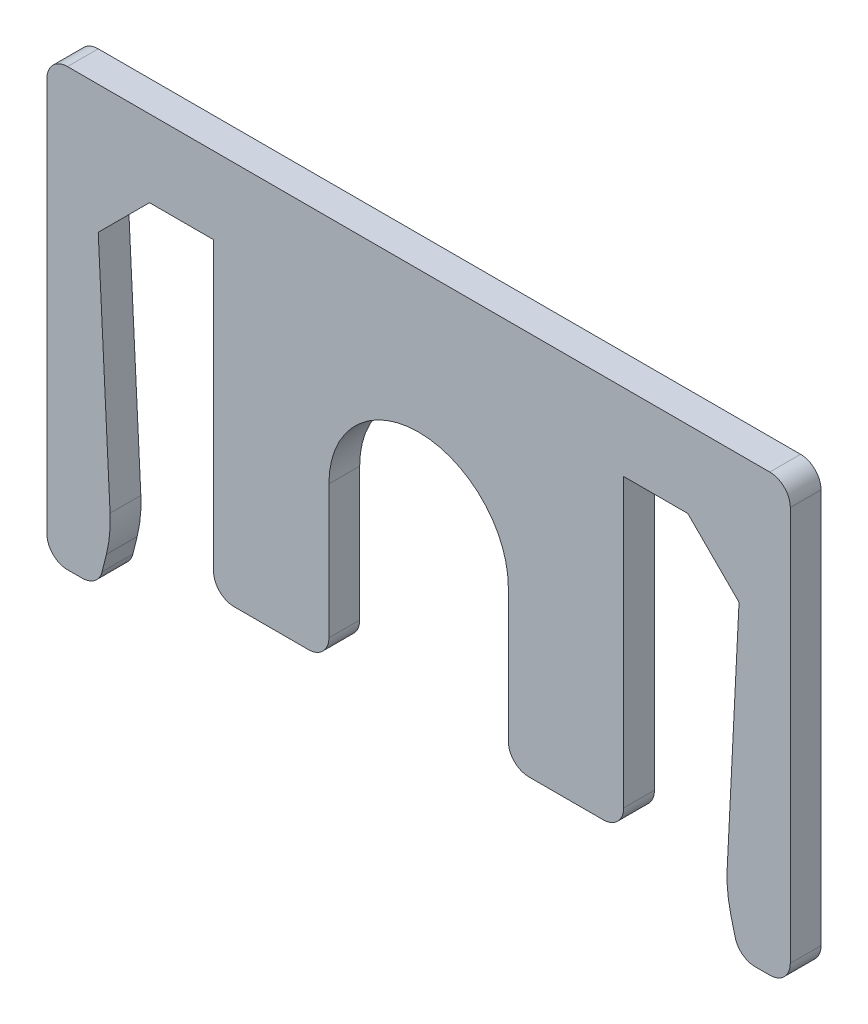
from build123d import *

# Parameters (mm, degrees)
BOSS_EXTRUDE1_DEPTH = 1.2
FILLET1_R           = 5
FILLET2_R           = 0.8


with BuildPart() as part:
    # Sketch1 → Boss-Extrude1 (new body)
    with BuildSketch(Plane.XY):
        with BuildLine():
            Line((-10.5, 0), (-12.5, -2))
            Line((-12.5, -2), (-12, -12))
            Line((-12, -12), (-12.5, -14))
            Line((-12.5, -14), (-14.5, -14))
            Line((-14.5, -14), (-14.5, 3))
            Line((-14.5, 3), (-12.5, 3))
            Line((-12.5, 3), (12.5, 3))
            Line((12.5, 3), (14.5, 3))
            Line((14.5, 3), (14.5, -14))
            Line((14.5, -14), (12.5, -14))
            Line((12.5, -14), (12, -12))
            Line((12, -12), (12.5, -2))
            Line((12.5, -2), (10.5, 0))
            Line((10.5, 0), (8, 0))
            Line((8, 0), (8, -12))
            Line((8, -12), (3.5, -12))
            Line((3.5, -12), (3.5, -6))
            ThreePointArc((3.5, -6), (0, -2.5), (-3.5, -6))
            Line((-3.5, -6), (-3.5, -12))
            Line((-3.5, -12), (-8, -12))
            Line((-8, -12), (-8, 0))
            Line((-8, 0), (-10.5, 0))
        make_face()
    extrude(amount=BOSS_EXTRUDE1_DEPTH)

    # Fillet1
    fillet1_edges = [part.edges().sort_by_distance(p)[0] for p in [
        (-12, -12, 0.6),
        (12, -12, 0.6),
    ]]
    fillet(fillet1_edges, radius=FILLET1_R)

    # Fillet2
    fillet2_edges = [part.edges().sort_by_distance(p)[0] for p in [
        (-12.5, -14, 0.6),
        (-14.5, -14, 0.6),
        (-14.5, 3, 0.6),
        (14.5, 3, 0.6),
        (14.5, -14, 0.6),
        (12.5, -14, 0.6),
        (8, -12, 0.6),
        (3.5, -12, 0.6),
        (-3.5, -12, 0.6),
        (-8, -12, 0.6),
    ]]
    fillet(fillet2_edges, radius=FILLET2_R)


solid = part.part
